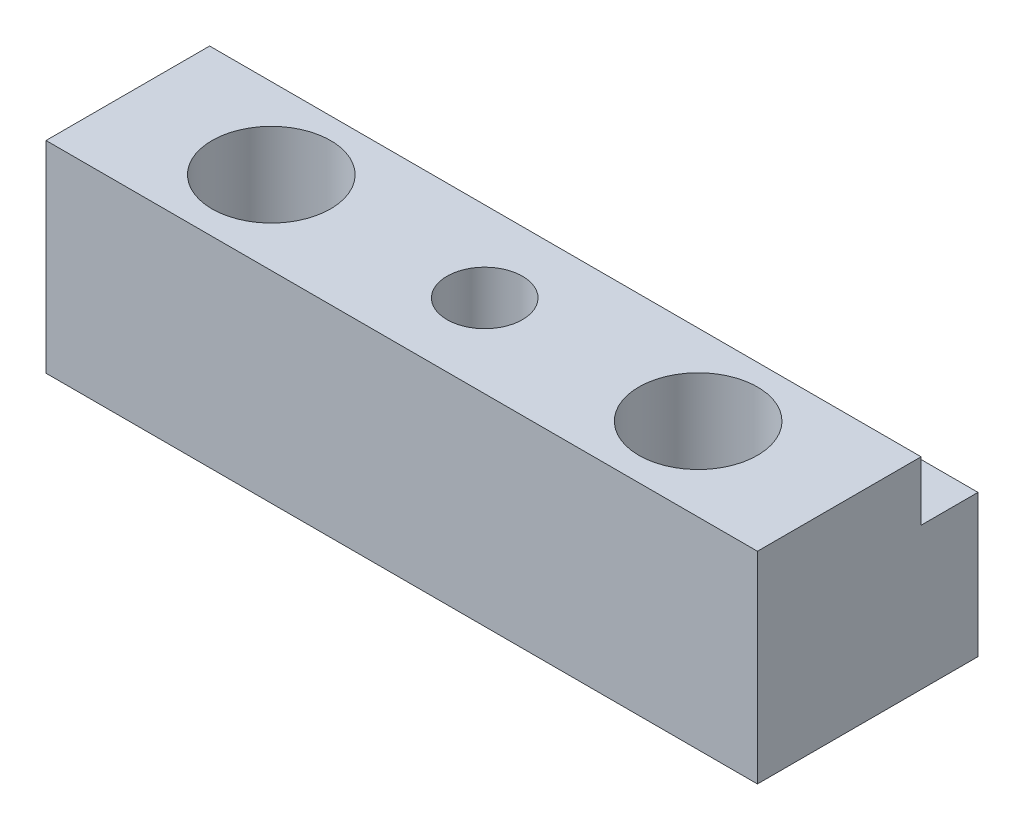
from build123d import *

# Parameters (mm, degrees)
SKETCH1_W                      = 38.1
SKETCH1_H                      = 11.811
BOSS_EXTRUDE1_DEPTH            = 10.795
SKETCH2_W                      = 38.1
SKETCH2_H                      = 3.048
CUT_EXTRUDE1_DEPTH             = 3.175
F_1_4_0_25_PRESS_DOWEL_HOLE1_D = 6.35
F_10_32_TAPPED_HOLE1_D         = 4.0386


with BuildPart() as part:
    # Sketch1 → Boss-Extrude1 (new body)
    with BuildSketch(Plane(origin=(0, 0, 0), x_dir=(1, 0, 0), z_dir=(0, 1, 0))):
        with Locations((19.05, 5.9055)):
            Rectangle(SKETCH1_W, SKETCH1_H)
    extrude(amount=BOSS_EXTRUDE1_DEPTH)

    # Sketch2 → Cut-Extrude1 (cut)
    with BuildSketch(Plane(origin=(0, 10.795, 0), x_dir=(1, 0, 0), z_dir=(0, 1, 0))):
        with Locations((19.05, 10.287)):
            Rectangle(SKETCH2_W, SKETCH2_H)
    extrude(amount=-CUT_EXTRUDE1_DEPTH, mode=Mode.SUBTRACT)

    # 1/4 (0.25) Press Dowel Hole1 (through all)
    with Locations(Plane(origin=(0, 10.795, 0), x_dir=(1, 0, 0), z_dir=(0, 1, 0))):
        with Locations((7.62, 4.445), (30.48, 4.445)):
            Hole(F_1_4_0_25_PRESS_DOWEL_HOLE1_D / 2)

    # #10-32 Tapped Hole1 (through all)
    with Locations(Plane(origin=(0, 10.795, 0), x_dir=(1, 0, 0), z_dir=(0, 1, 0))):
        with Locations((19.05, 4.445)):
            Hole(F_10_32_TAPPED_HOLE1_D / 2)


solid = part.part
